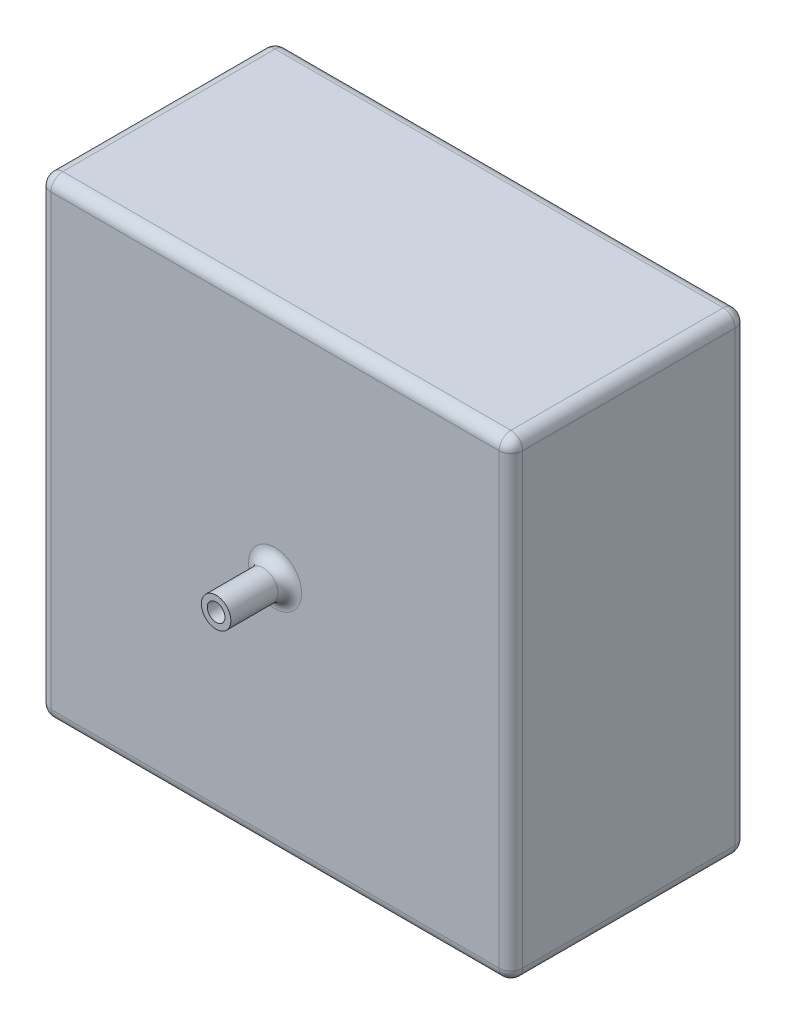
from build123d import *

# Parameters (mm, degrees)
SKETCH_1_W      = 400
SKETCH_1_H      = 400
EXTRUDE_1_DEPTH = 200
SKETCH_2_R      = 12.5
EXTRUDE_2_DEPTH = 50
FILLET_1_R      = 10
SHELL_1_T       = -5


with BuildPart() as part:
    # 스케치1 → 보스-돌출1 (new body)
    with BuildSketch(Plane.XY):
        with Locations((200, -200)):
            Rectangle(SKETCH_1_W, SKETCH_1_H)
    extrude(amount=EXTRUDE_1_DEPTH)

    # 스케치2 → 보스-돌출2 (add)
    with BuildSketch(Plane.XY.offset(200)):
        with Locations((200, -198.566815637)):
            Circle(SKETCH_2_R)
    extrude(amount=EXTRUDE_2_DEPTH)

    # 필렛1
    fillet_1_edges = [part.edges().sort_by_distance(p)[0] for p in [
        (400, -200, 200),
        (200, 0, 200),
        (187.5, -198.566815637, 200),
        (0, -200, 200),
        (200, 0, 0),
        (400, -200, 0),
        (200, -400, 0),
        (0, -200, 0),
        (200, -400, 200),
        (0, 0, 100),
        (400, 0, 100),
        (400, -400, 100),
        (0, -400, 100),
    ]]
    fillet(fillet_1_edges, radius=FILLET_1_R)

    # 쉘1
    shell_1_openings = [part.faces().sort_by_distance(p)[0] for p in [
        (200, -198.566815637, 250),
    ]]
    offset(amount=SHELL_1_T, openings=shell_1_openings, kind=Kind.INTERSECTION)


solid = part.part
